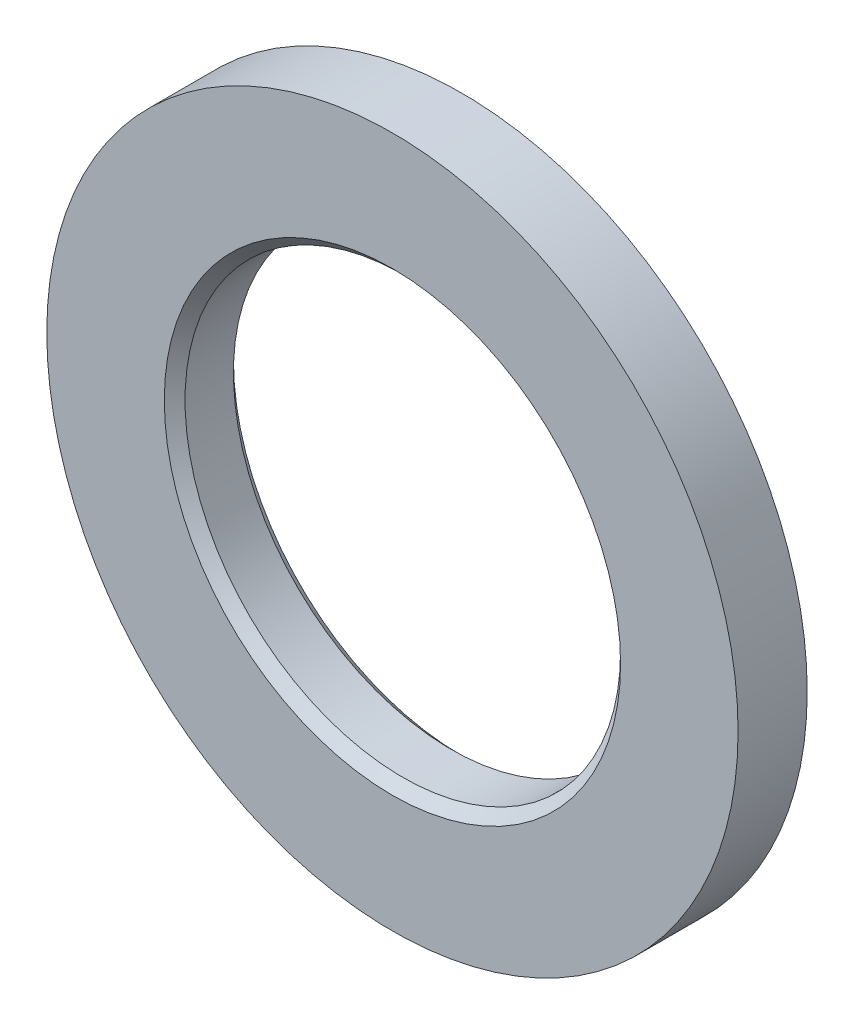
from build123d import *

# Parameters (mm, degrees)
GUARD_BASE_R     = 25
GUARD_DEPTH      = 5
AXLE_HOLE_BASE_R = 15.75
AXLE_HOLE_DEPTH  = 6


with BuildPart() as part:
    # Guard base → Guard (new body)
    with BuildSketch(Plane.XY):
        Circle(GUARD_BASE_R)
    extrude(amount=GUARD_DEPTH)

    # Axle hole base → Axle hole (cut, through all)
    with BuildSketch(Plane.XY.offset(5)):
        Circle(AXLE_HOLE_BASE_R)
    extrude(amount=-AXLE_HOLE_DEPTH, mode=Mode.SUBTRACT)

    # Mate ring room base → Mate ring room (revolve, cut)
    with BuildSketch(Plane(origin=(0, 0, 0), x_dir=(1, 0, 0), z_dir=(0, 1, 0))):
        Polygon((15.75, -5), (16.5, -5), (15.75, -4.25), align=None)
        Polygon((15.75, 0), (16.5, 0), (15.75, -0.75), align=None)
    revolve(axis=Axis((0, 0, 0), (0, 0, -1)), mode=Mode.SUBTRACT)


solid = part.part
